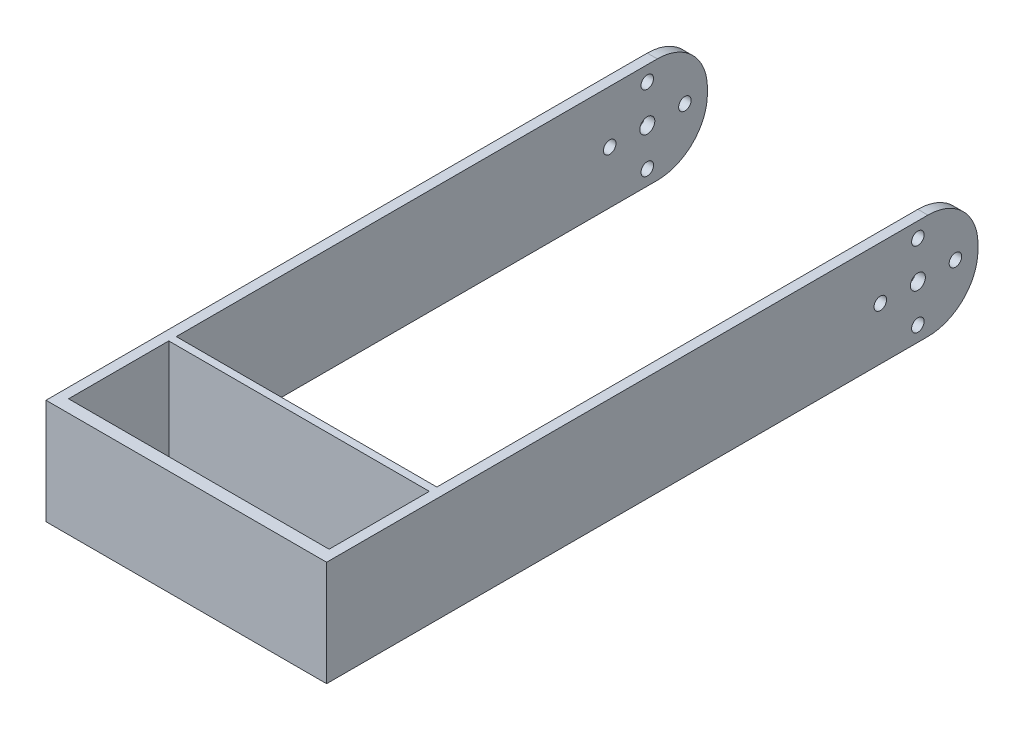
from build123d import *

# Parameters (mm, degrees)
SKETCH3_W           = 56
SKETCH3_H           = 21
BOSS_EXTRUDE1_DEPTH = 130
SKETCH4_W           = 52
SKETCH4_H           = 106
SKETCH4_H_2         = 20
CUT_EXTRUDE3_DEPTH  = 22
SKETCH6_R           = 1.5
SKETCH6_R_2         = 1.25
CUT_EXTRUDE4_DEPTH  = 57
FILLET1_R           = 10


with BuildPart() as part:
    # Sketch3 → Boss-Extrude1 (new body)
    with BuildSketch(Plane.XY):
        Rectangle(SKETCH3_W, SKETCH3_H)
    extrude(amount=BOSS_EXTRUDE1_DEPTH)

    # Sketch4 → Cut-Extrude3 (cut, through all)
    with BuildSketch(Plane.XZ.offset(10.5)):
        with Locations((0, 53)):
            Rectangle(SKETCH4_W, SKETCH4_H)
        with Locations((0, 117.5)):
            Rectangle(SKETCH4_W, SKETCH4_H_2)
    extrude(amount=-CUT_EXTRUDE3_DEPTH, mode=Mode.SUBTRACT)

    # Sketch6 → Cut-Extrude4 (cut, through all)
    with BuildSketch(Plane(origin=(28, 0, 0), x_dir=(0, 0, -1), z_dir=(1, 0, 0))):
        with Locations((-12, 0)):
            Circle(SKETCH6_R)
        with Locations((-4.5, 0)):
            Circle(SKETCH6_R_2)
        with Locations((-19.5, 0)):
            Circle(SKETCH6_R_2)
        with Locations((-12, 7.5)):
            Circle(SKETCH6_R_2)
        with Locations((-12, -7.5)):
            Circle(SKETCH6_R_2)
    extrude(amount=-CUT_EXTRUDE4_DEPTH, mode=Mode.SUBTRACT)

    # Fillet1
    fillet1_edges = [part.edges().sort_by_distance(p)[0] for p in [
        (27, -10.5, 0),
        (-27, 10.5, 0),
        (-27, -10.5, 0),
        (27, 10.5, 0),
    ]]
    fillet(fillet1_edges, radius=FILLET1_R)


solid = part.part
